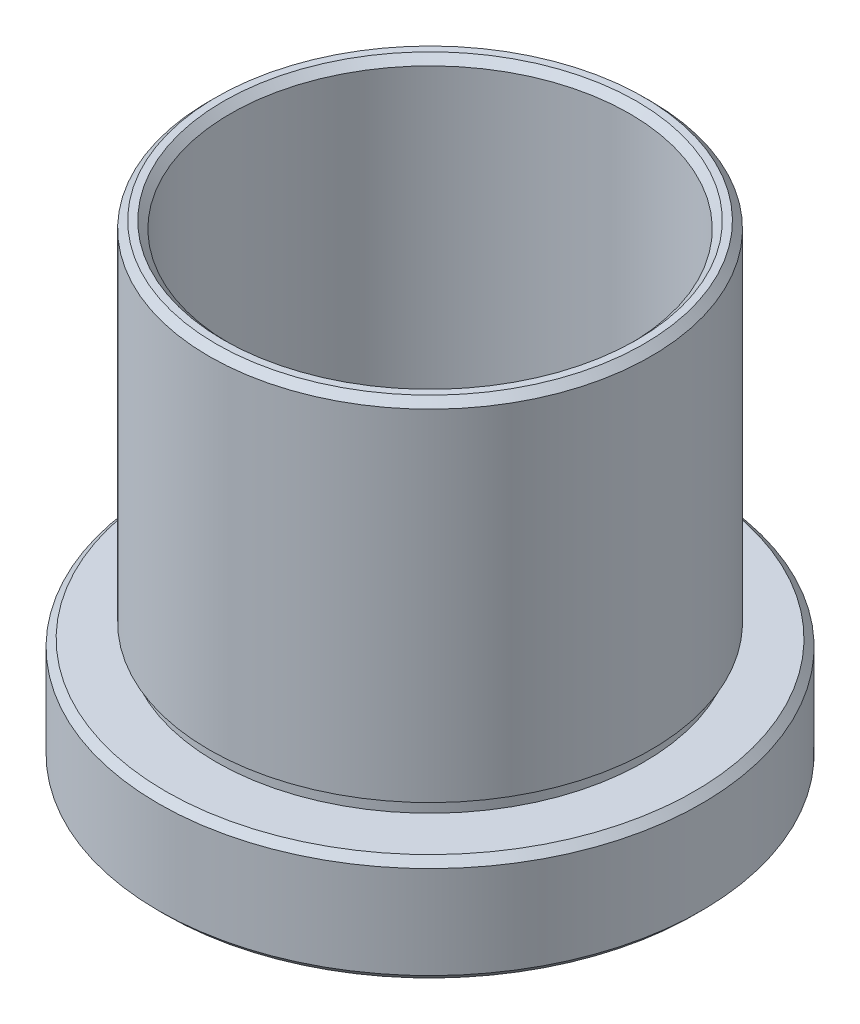
from build123d import *


with BuildPart() as part:
    # 草图1 → 旋转2 (revolve)
    with BuildSketch(Plane.XY, mode=Mode.PRIVATE) as revolve_2_sk:
        Polygon((14.5, 27.042854175), (15, 27.042854175), (15.5, 26.542854175), (15.5, 2.642854175), (15, 2.642854175), (15, 1.642854175), (18.55, 1.642854175), (19.05, 1.142854175), (19.05, -5.357145825), (18.55, -5.857145825), (18, -5.857145825), (17.5, -5.357145825), (17.5, -1.357145825), (17.6, -1.357145825), (17.6, -0.357145825), (14, -0.357145825), (14, 26.542854175), align=None)
    revolve(revolve_2_sk.sketch.rotate(Axis((0, 44.598597745, 0), (0, -1, 0)), 90), axis=Axis((0, 44.598597745, 0), (0, -1, 0)))  # turned: the seam where the file's is


solid = part.part
